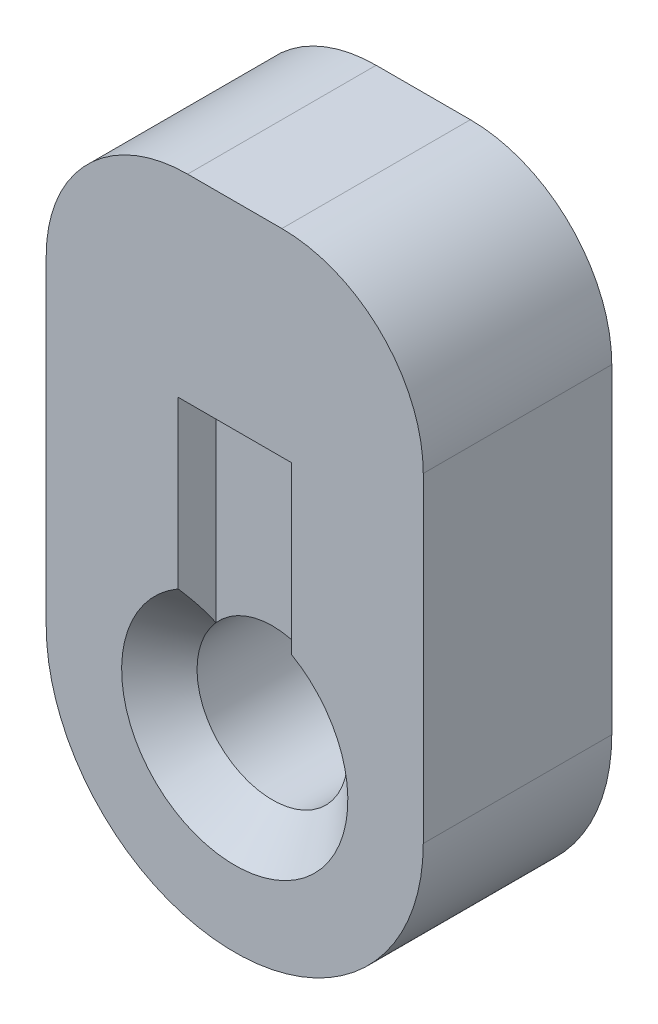
from build123d import *

# Parameters (mm, degrees)
SKETCH2_R           = 1.016
BOSS_EXTRUDE2_DEPTH = 2.54
CUT_EXTRUDE1_DEPTH  = 0.508
CUT_EXTRUDE2_DEPTH  = 0.508


with BuildPart() as part:
    # Sketch2 → Boss-Extrude2 (new body)
    with BuildSketch(Plane.XY):
        with BuildLine():
            ThreePointArc((-2.54, 0), (0, -2.54), (2.54, 0))
            Line((2.54, 0), (2.54, 4.318))
            ThreePointArc((2.54, 4.318), (1.982038418, 5.665038418), (0.635, 6.223))
            Line((0.635, 6.223), (-0.635, 6.223))
            ThreePointArc((-0.635, 6.223), (-1.982038418, 5.665038418), (-2.54, 4.318))
            Line((-2.54, 4.318), (-2.54, 0))
        make_face()
        Circle(SKETCH2_R, mode=Mode.SUBTRACT)
    extrude(amount=BOSS_EXTRUDE2_DEPTH)

    # Sketch3 → Cut-Extrude1 (cut)
    with BuildSketch(Plane.XY.offset(2.54)):
        with BuildLine():
            Line((-0.762, 2.423005572), (-0.762, 1.319822715))
            ThreePointArc((-0.762, 1.319822715), (0, 1.524), (0.762, 1.319822715))
            Line((0.762, 1.319822715), (0.762, 2.423005572))
            ThreePointArc((0.762, 2.423005572), (0, 2.54), (-0.762, 2.423005572))
        make_face()
        with BuildLine():
            Line((-0.762, 3.556), (-0.762, 2.423005572))
            ThreePointArc((-0.762, 2.423005572), (0, 2.54), (0.762, 2.423005572))
            Line((0.762, 2.423005572), (0.762, 3.556))
            Line((0.762, 3.556), (-0.762, 3.556))
        make_face()
        with BuildLine():
            Line((-0.762, 1.319822715), (-0.762, 0.672020833))
            ThreePointArc((-0.762, 0.672020833), (0, 1.016), (0.762, 0.672020833))
            Line((0.762, 0.672020833), (0.762, 1.319822715))
            ThreePointArc((0.762, 1.319822715), (0, 1.524), (-0.762, 1.319822715))
        make_face()
    extrude(amount=-CUT_EXTRUDE1_DEPTH, mode=Mode.SUBTRACT)

    # Sketch4 → Cut-Extrude2 (cut)
    with BuildSketch(Plane(origin=(0, 0, 0), x_dir=(-1, 0, 0), z_dir=(0, 0, -1))):
        with BuildLine():
            ThreePointArc((-0.762, 2.423005572), (0, 2.54), (0.762, 2.423005572))
            Line((0.762, 2.423005572), (0.762, 3.556))
            Line((0.762, 3.556), (-0.762, 3.556))
            Line((-0.762, 3.556), (-0.762, 2.423005572))
        make_face()
        with BuildLine():
            Line((0.762, 1.319822715), (0.762, 2.423005572))
            ThreePointArc((0.762, 2.423005572), (0, 2.54), (-0.762, 2.423005572))
            Line((-0.762, 2.423005572), (-0.762, 1.319822715))
            ThreePointArc((-0.762, 1.319822715), (0, 1.524), (0.762, 1.319822715))
        make_face()
        with BuildLine():
            Line((0.762, 0.672020833), (0.762, 1.319822715))
            ThreePointArc((0.762, 1.319822715), (0, 1.524), (-0.762, 1.319822715))
            Line((-0.762, 1.319822715), (-0.762, 0.672020833))
            ThreePointArc((-0.762, 0.672020833), (0, 1.016), (0.762, 0.672020833))
        make_face()
    extrude(amount=-CUT_EXTRUDE2_DEPTH, mode=Mode.SUBTRACT)

    # Sketch7 → Cut-Revolve1 (revolve, cut)
    with BuildSketch(Plane(origin=(0, 0, 0), x_dir=(1, 0, 0), z_dir=(0, 1, 0))):
        Polygon((0, 0), (0, -2.54), (1.524, -2.54), (0.508, -1.524), (0.508, -1.016), (1.524, 0), align=None)
    revolve(axis=Axis((0, 0, 0), (0, 0, 1)), mode=Mode.SUBTRACT)


solid = part.part
